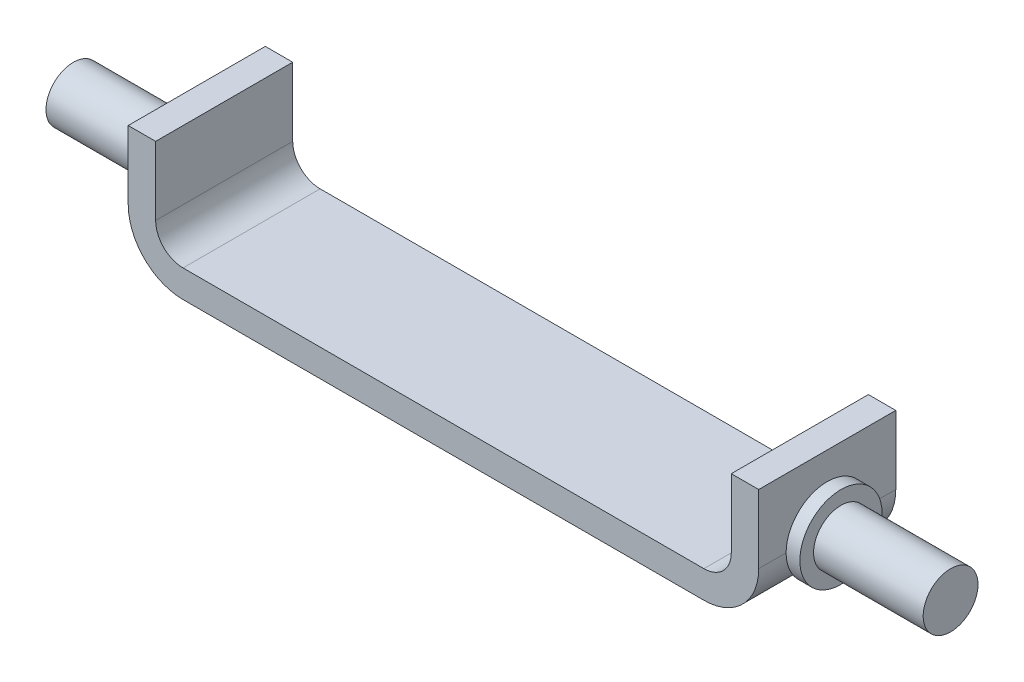
from build123d import *

# Parameters (mm, degrees)
EXTRUDE_THIN2_DEPTH  = 50
SKETCH3_R            = 10
BOSS_EXTRUDE7_DEPTH  = 45
SKETCH8_R            = 10
BOSS_EXTRUDE8_DEPTH  = 45
SKETCH9_R            = 15
BOSS_EXTRUDE9_DEPTH  = 5
SKETCH10_R           = 15
BOSS_EXTRUDE10_DEPTH = 5


with BuildPart() as part:
    # Sketch1 → Extrude-Thin2 (new body)
    with BuildSketch(Plane.XY):
        with BuildLine():
            Line((-106.417898558, 35), (-106.417898558, 10))
            ThreePointArc((-106.417898558, 10), (-103.48896637, 2.928932188), (-96.417898558, 0))
            Line((-96.417898558, 0), (93.582101442, 0))
            ThreePointArc((93.582101442, 0), (100.653169254, 2.928932188), (103.582101442, 10))
            Line((103.582101442, 10), (103.582101442, 35))
            Line((103.582101442, 35), (113.582101442, 35))
            Line((113.582101442, 35), (113.582101442, 10))
            ThreePointArc((113.582101442, 10), (107.724237066, -4.142135624), (93.582101442, -10))
            Line((93.582101442, -10), (-96.417898558, -10))
            ThreePointArc((-96.417898558, -10), (-110.560034182, -4.142135624), (-116.417898558, 10))
            Line((-116.417898558, 10), (-116.417898558, 35))
            Line((-116.417898558, 35), (-106.417898558, 35))
        make_face()
    extrude(amount=EXTRUDE_THIN2_DEPTH)

    # Sketch3 → Boss-Extrude7 (add)
    with BuildSketch(Plane(origin=(113.582101442, 0, 0), x_dir=(0, 0, -1), z_dir=(1, 0, 0))):
        with Locations((-25, 10)):
            Circle(SKETCH3_R)
    extrude(amount=BOSS_EXTRUDE7_DEPTH)

    # Sketch8 → Boss-Extrude8 (add)
    with BuildSketch(Plane.ZY.offset(116.417898558)):
        with Locations((25, 10)):
            Circle(SKETCH8_R)
    extrude(amount=BOSS_EXTRUDE8_DEPTH)

    # Sketch9 → Boss-Extrude9 (add)
    with BuildSketch(Plane.ZY.offset(116.417898558)):
        with Locations((25, 10)):
            Circle(SKETCH9_R)
    extrude(amount=BOSS_EXTRUDE9_DEPTH)

    # Sketch10 → Boss-Extrude10 (add)
    with BuildSketch(Plane(origin=(113.582101442, 0, 0), x_dir=(0, 0, -1), z_dir=(1, 0, 0))):
        with Locations((-25, 10)):
            Circle(SKETCH10_R)
    extrude(amount=BOSS_EXTRUDE10_DEPTH)


solid = part.part
